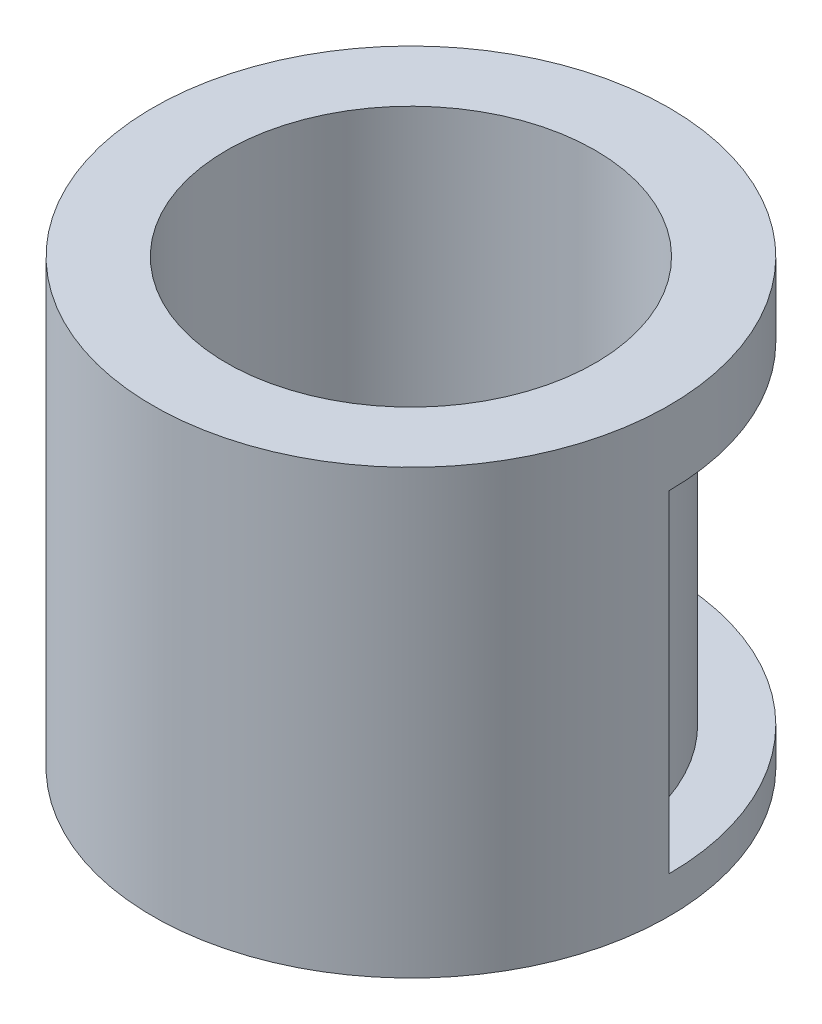
from build123d import *

# Parameters (mm, degrees)
SKETCH1_W          = 25.4
SKETCH1_H          = 152.4
SKETCH2_W          = 19.05
SKETCH2_H          = 114.3
CUT_REVOLVE1_ANGLE = 120


with BuildPart() as part:
    # Sketch1 → Revolve1 (revolve)
    with BuildSketch(Plane.XY):
        with Locations((76.2, 76.2)):
            Rectangle(SKETCH1_W, SKETCH1_H)
    revolve(axis=Axis((0, 0, 0), (0, 1, 0)))

    # Sketch2 → Cut-Revolve1 (revolve, cut)
    with BuildSketch(Plane.XY):
        with Locations((79.375, 69.85)):
            Rectangle(SKETCH2_W, SKETCH2_H)
    revolve(axis=Axis((0, 0, 0), (0, 1, 0)), revolution_arc=CUT_REVOLVE1_ANGLE, mode=Mode.SUBTRACT)


solid = part.part
